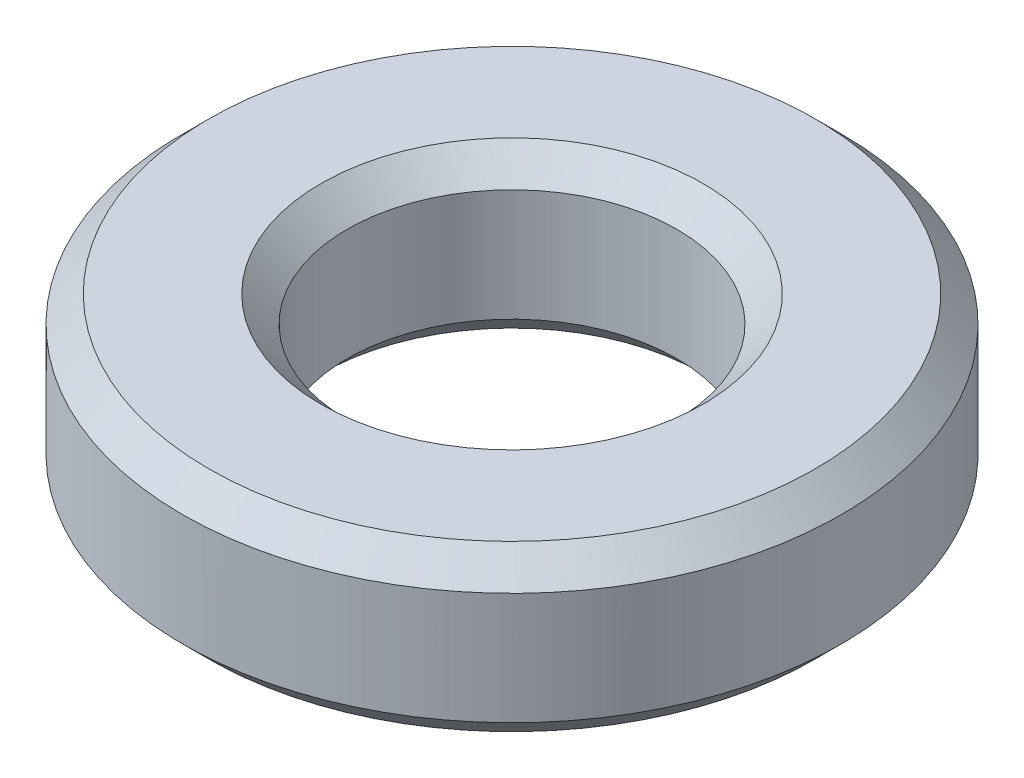
from build123d import *

# Parameters (mm, degrees)
SKETCH1_W     = 1.5875
SKETCH1_H     = 1.5875
CHAMFER1_SIZE = 0.254


with BuildPart() as part:
    # Sketch1 → Revolve1 (revolve)
    with BuildSketch(Plane.XY):
        with Locations((2.38125, 0)):
            Rectangle(SKETCH1_W, SKETCH1_H)
    revolve(axis=Axis((0, 0, 0), (0, 1, 0)))

    # Chamfer1
    chamfer1_edges = [part.edges().sort_by_distance(p)[0] for p in [
        (-1.5875, -0.79375, 0),
        (-3.175, -0.79375, 0),
        (-3.175, 0.79375, 0),
        (-1.5875, 0.79375, 0),
    ]]
    chamfer(chamfer1_edges, length=CHAMFER1_SIZE)


solid = part.part
